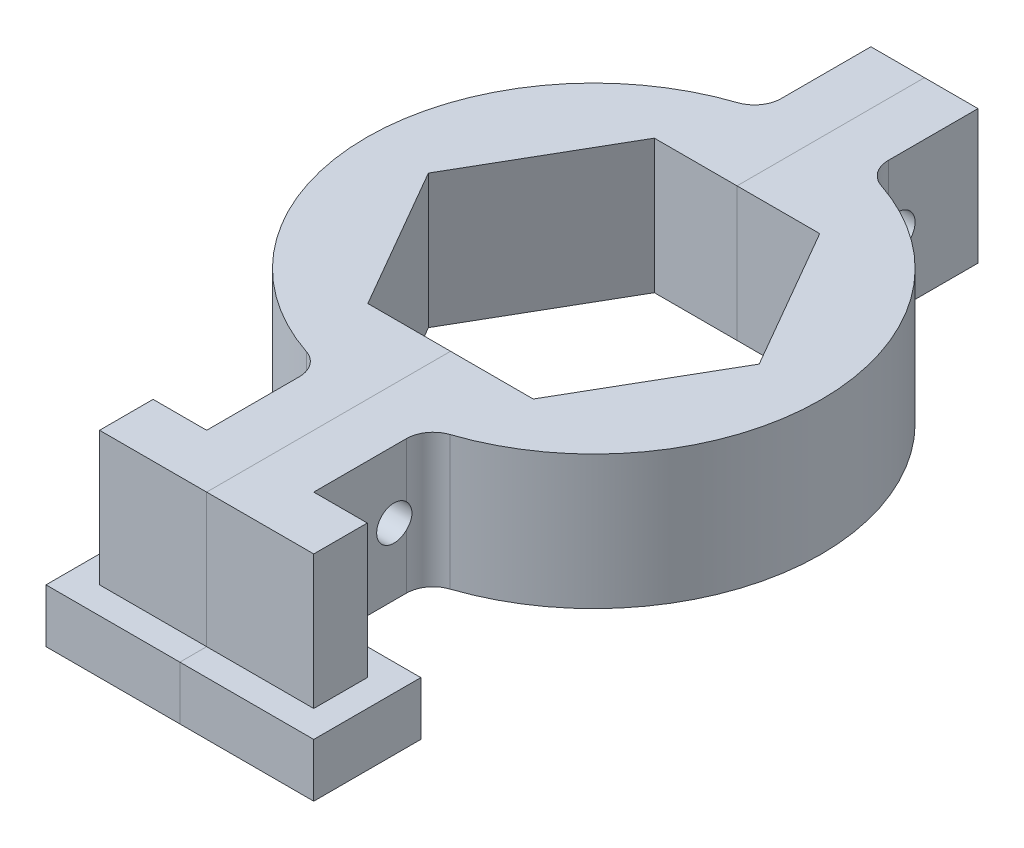
from build123d import *

# Parameters (mm, degrees)
BOSS_EXTRUDE1_DEPTH     = 12.7
SKETCH2_R               = 1.651
CUT_EXTRUDE1_DEPTH      = 17.477104351
CUT_EXTRUDE1_DEPTH_BACK = 6.08
SKETCH3_W               = 12.7
SKETCH3_H               = 10.16
BOSS_EXTRUDE2_DEPTH     = 5.08


with BuildPart() as part:
    # Sketch1 → Boss-Extrude1 (new body)
    with BuildSketch(Plane(origin=(0, 0, 0), x_dir=(1, 0, 0), z_dir=(0, 1, 0))):
        with BuildLine():
            Line((-5.08, 13.589), (0, 13.589))
            Line((0, 13.589), (0, 18.669))
            Line((0, 18.669), (0, 31.369))
            Line((0, 31.369), (-5.08, 31.369))
            Line((-5.08, 31.369), (-5.08, 22.860578254))
            ThreePointArc((-5.08, 22.860578254), (-5.559450485, 21.375406313), (-6.81679976, 20.450916582))
            ThreePointArc((-6.81679976, 20.450916582), (-21.557104351, 0), (-6.81679976, -20.450916582))
            ThreePointArc((-6.81679976, -20.450916582), (-5.559450485, -21.375406313), (-5.08, -22.860578254))
            Line((-5.08, -22.860578254), (-5.08, -31.6484))
            Line((-5.08, -31.6484), (-10.16, -31.6484))
            Line((-10.16, -31.6484), (-10.16, -36.7284))
            Line((-10.16, -36.7284), (-5.08, -36.7284))
            Line((-5.08, -36.7284), (0, -36.7284))
            Line((0, -36.7284), (0, -31.6484))
            Line((0, -31.6484), (0, -18.669))
            Line((0, -18.669), (0, -13.589))
            Line((0, -13.589), (-5.08, -13.589))
            Line((-5.08, -13.589), (-7.845612808, -13.589))
            Line((-7.845612808, -13.589), (-15.691225616, 0))
            Line((-15.691225616, 0), (-7.845612808, 13.589))
            Line((-7.845612808, 13.589), (-5.08, 13.589))
        make_face()
    extrude(amount=BOSS_EXTRUDE1_DEPTH)

    # Sketch2 → Cut-Extrude1 (cut, two sides)
    with BuildSketch(Plane.ZY.offset(5.08)) as cut_extrude1_sk:
        with BuildLine():
            ThreePointArc((-22.860578254, 4.958415363), (-22.301142047, 5.556584378), (-22.098, 6.35))
            ThreePointArc((-22.098, 6.35), (-22.301142047, 7.143415622), (-22.860578254, 7.741584637))
            Line((-22.860578254, 7.741584637), (-22.860578254, 4.958415363))
        make_face()
        with BuildLine():
            Line((-22.860578254, 4.958415363), (-22.860578254, 7.741584637))
            ThreePointArc((-22.860578254, 7.741584637), (-25.4, 6.35), (-22.860578254, 4.958415363))
        make_face()
        with Locations((24.0284, 6.35)):
            Circle(SKETCH2_R)
    extrude(amount=CUT_EXTRUDE1_DEPTH, mode=Mode.SUBTRACT)
    extrude(cut_extrude1_sk.sketch, amount=-CUT_EXTRUDE1_DEPTH_BACK, mode=Mode.SUBTRACT)

    # Sketch3 → Boss-Extrude2 (add)
    with BuildSketch(Plane.XZ):
        with Locations((-6.35, 34.1884)):
            Rectangle(SKETCH3_W, SKETCH3_H)
    extrude(amount=BOSS_EXTRUDE2_DEPTH)


with BuildPart() as body_2:
    # Mirror1: mirrored copy
    add(part.part.mirror(Plane(origin=(0, 12.7, 0), x_dir=(0, 0, 1), z_dir=(1, 0, 0))))


solid = Compound([part.part, body_2.part])
